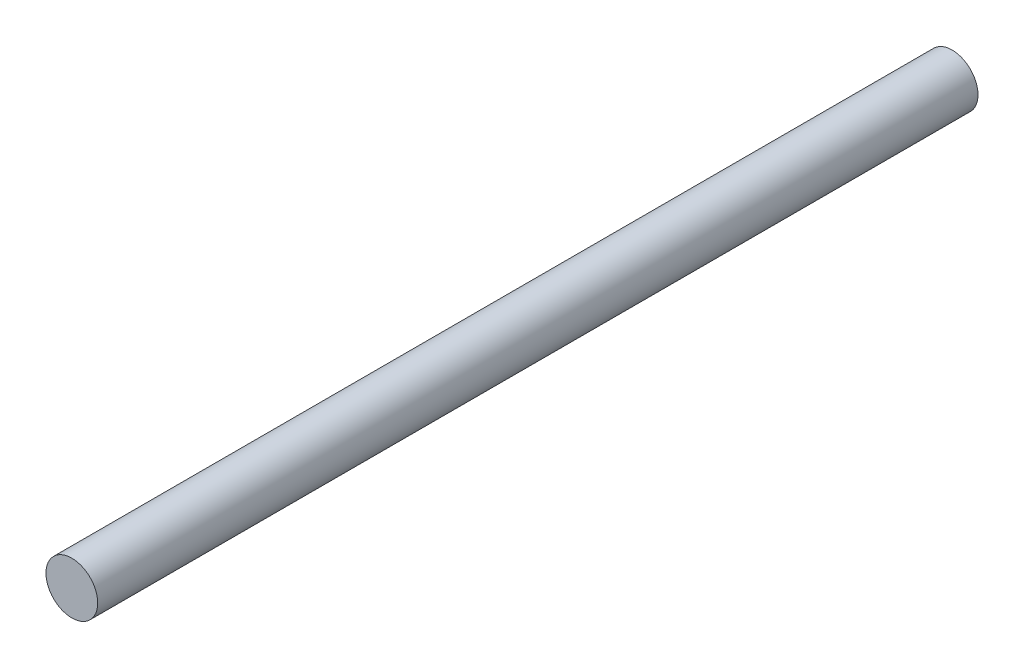
from build123d import *

# Parameters (mm, degrees)
SKETCH1_R           = 6.35
BOSS_EXTRUDE1_DEPTH = 215.9


with BuildPart() as part:
    # Sketch1 → Boss-Extrude1 (new body)
    with BuildSketch(Plane.XY):
        Circle(SKETCH1_R)
    extrude(amount=BOSS_EXTRUDE1_DEPTH)


solid = part.part
